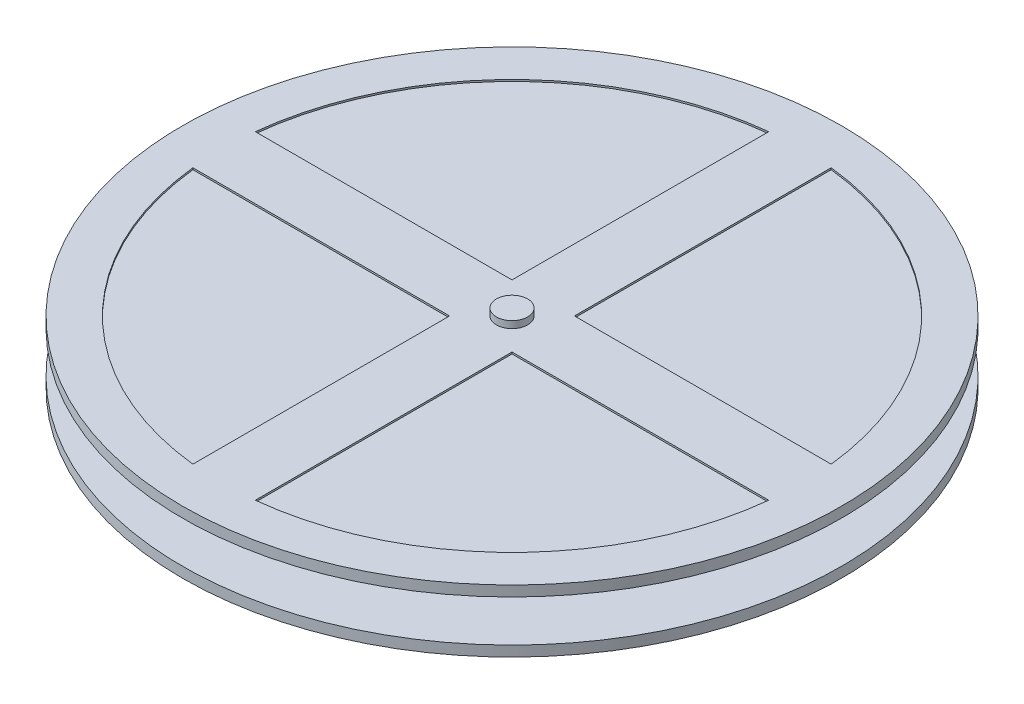
from build123d import *

# Parameters (mm, degrees)
SKETCH2_W           = 78
SKETCH2_H           = 21
SKETCH2_W_2         = 10
SKETCH2_H_2         = 10
BOSS_EXTRUDE1_DEPTH = 50
CHAMFER1_SIZE       = 2.5
CHAMFER2_SIZE       = 0.5
SKETCH3_R           = 4.5
BOSS_EXTRUDE2_DEPTH = 25
BOSS_EXTRUDE3_START = 5
SKETCH4_R           = 95
SKETCH4_R_2         = 4.5
BOSS_EXTRUDE3_DEPTH = 18
SKETCH5_W           = 86
SKETCH5_H           = 12
CUT_EXTRUDE1_DEPTH  = 0.5
CIRPATTERN1_COUNT   = 4


with BuildPart() as part:
    # Sketch2 → Boss-Extrude1 (new body)
    with BuildSketch(Plane.XY):
        Rectangle(SKETCH2_W, SKETCH2_H)
        with Locations((-31, 4)):
            Rectangle(SKETCH2_W_2, SKETCH2_H_2, mode=Mode.SUBTRACT)
        with Locations((31, 4)):
            Rectangle(SKETCH2_W_2, SKETCH2_H_2, mode=Mode.SUBTRACT)
    extrude(amount=BOSS_EXTRUDE1_DEPTH)

    # Chamfer1
    chamfer1_edges = [part.edges().sort_by_distance(p)[0] for p in [
        (39, -10.5, 25),
        (-39, -10.5, 25),
    ]]
    chamfer(chamfer1_edges, length=CHAMFER1_SIZE)

    # Chamfer2
    chamfer2_edges = [part.edges().sort_by_distance(p)[0] for p in [
        (-39, 10.5, 25),
        (39, 10.5, 25),
    ]]
    chamfer(chamfer2_edges, length=CHAMFER2_SIZE)

    # Sketch3 → Boss-Extrude2 (add)
    with BuildSketch(Plane(origin=(0, 10.5, 0), x_dir=(1, 0, 0), z_dir=(0, 1, 0))):
        with Locations((0, -25)):
            Circle(SKETCH3_R)
    extrude(amount=BOSS_EXTRUDE2_DEPTH)

    # Sketch4 → Boss-Extrude3 (add)
    with BuildSketch(Plane(origin=(0, 10.5, 0), x_dir=(1, 0, 0), z_dir=(0, 1, 0)).offset(BOSS_EXTRUDE3_START)):
        with Locations((0, -25)):
            Circle(SKETCH4_R)
        with Locations((0, -25)):
            Circle(SKETCH4_R_2, mode=Mode.SUBTRACT)
    extrude(amount=BOSS_EXTRUDE3_DEPTH)

    # Sketch5 → Cut-Revolve1 (revolve, cut)
    with BuildSketch(Plane(origin=(0, 0, 0), x_dir=(0, 0, -1), z_dir=(1, 0, 0))):
        with Locations((27, 24.5)):
            Rectangle(SKETCH5_W, SKETCH5_H)
    revolve(axis=Axis((0, 10.5, 25), (0, 1, 0)), mode=Mode.SUBTRACT)

    # Sketch6 → Cut-Extrude1 (cut)
    with BuildSketch(Plane(origin=(0, 33.5, 0), x_dir=(1, 0, 0), z_dir=(0, 1, 0))):
        with BuildLine():
            Line((9, 58.006582115), (9, -16))
            Line((9, -16), (83.006582115, -16))
            ThreePointArc((83.006582115, -16), (59.03851571, 34.03851571), (9, 58.006582115))
        make_face()
    cut_extrude1 = extrude(amount=-CUT_EXTRUDE1_DEPTH, mode=Mode.SUBTRACT)

    # CirPattern1: Cut-Extrude1 ×4 about axis
    cirpattern1_axis = Axis((0, 0, 25), (0, 1, 0))
    for i in range(1, CIRPATTERN1_COUNT):
        add(cut_extrude1.rotate(cirpattern1_axis, i * 360 / CIRPATTERN1_COUNT), mode=Mode.SUBTRACT)


solid = part.part
